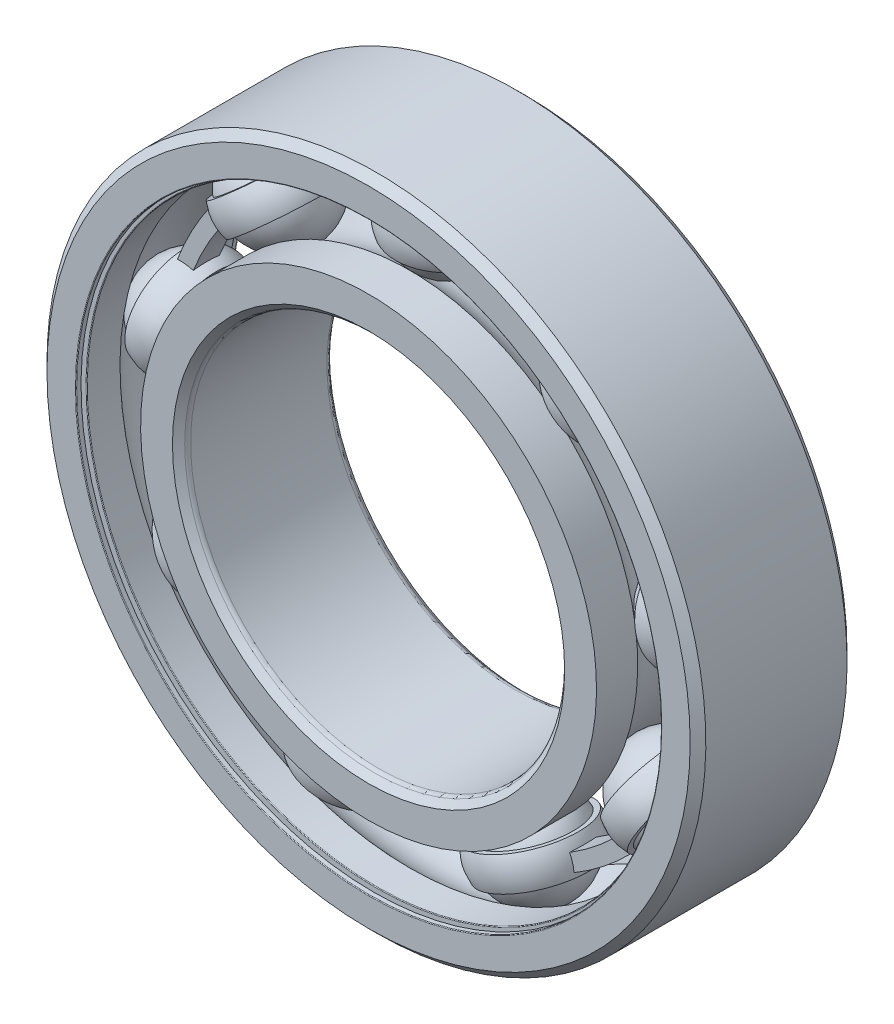
from build123d import *

# Parameters (mm, degrees)
BOSS_EXTRUDE1_DEPTH = 0.416666667
CIRPATTERN1_COUNT   = 9
CIRPATTERN2_COUNT   = 9
FILLET1_R           = 0.0225
FILLET2_R           = 0.1875


with BuildPart() as part:
    # Sketch3 → Revolve1 (revolve)
    with BuildSketch(Plane(origin=(0, 0, 0), x_dir=(0, 0, -1), z_dir=(1, 0, 0))):
        with BuildLine():
            Line((2.25, 10.5), (2.5, 10.25))
            Line((2.5, 10.25), (2.5, 9.234615385))
            Line((2.5, 9.234615385), (1.1875, 9.234615385))
            ThreePointArc((1.1875, 9.234615385), (0, 9.7926029), (-1.1875, 9.234615385))
            Line((-1.1875, 9.234615385), (-2.5, 9.234615385))
            Line((-2.5, 9.234615385), (-2.5, 10.25))
            Line((-2.5, 10.25), (-2.25, 10.5))
            Line((-2.25, 10.5), (2.25, 10.5))
        make_face()
    revolve(axis=Axis((0, 0, 2.5), (0, 0, -1)))

    # Sketch8 → Cut-Revolve1 (revolve, cut)
    with BuildSketch(Plane(origin=(0, 0, 0), x_dir=(0, 0, -1), z_dir=(1, 0, 0))):
        Polygon((-2.34, 9.234615385), (-2.25, 9.234615385), (-2.25, 9.656410256), (-2.34, 9.656410256), (-2.34, 9.324615385), (-2.5, 9.324615385), (-2.5, 9.234615385), align=None)
        Polygon((2.25, 9.234615385), (2.34, 9.234615385), (2.5, 9.234615385), (2.5, 9.324615385), (2.34, 9.324615385), (2.34, 9.656410256), (2.25, 9.656410256), align=None)
    revolve(axis=Axis((0, 0, 2.5), (0, 0, -1)), mode=Mode.SUBTRACT)

    # Fillet1
    fillet1_edges = [part.edges().sort_by_distance(p)[0] for p in [
        (0, -9.324615385, 2.5),
        (0, -9.234615385, 2.25),
        (0, -9.324615385, -2.5),
        (0, -9.234615385, -2.25),
    ]]
    fillet(fillet1_edges, radius=FILLET1_R)


with BuildPart() as body_2:
    # Sketch4 → Revolve2 (revolve)
    with BuildSketch(Plane(origin=(0, 0, 0), x_dir=(0, 0, -1), z_dir=(1, 0, 0))):
        with BuildLine():
            Line((-2.25, 6), (-2.5, 6.25))
            Line((-2.5, 6.25), (-2.5, 7.265384615))
            Line((-2.5, 7.265384615), (-1.1875, 7.265384615))
            ThreePointArc((-1.1875, 7.265384615), (0, 6.7073971), (1.1875, 7.265384615))
            Line((1.1875, 7.265384615), (2.5, 7.265384615))
            Line((2.5, 7.265384615), (2.5, 6.25))
            Line((2.5, 6.25), (2.25, 6))
            Line((2.25, 6), (-2.25, 6))
        make_face()
    revolve(axis=Axis((0, 0, 2.5), (0, 0, -1)))

    # Fillet2
    fillet2_edges = [body_2.edges().sort_by_distance(p)[0] for p in [
        (0, -6, 2.25),
        (0, -6, -2.25),
    ]]
    fillet(fillet2_edges, radius=FILLET2_R)


with BuildPart() as body_3:
    # Sketch5 → Revolve3 (revolve)
    with BuildSketch(Plane(origin=(0, 0, 0), x_dir=(0, 0, -1), z_dir=(1, 0, 0))):
        with BuildLine():
            Line((-1.5426029, 8.25), (1.5426029, 8.25))
            ThreePointArc((1.5426029, 8.25), (0, 9.7926029), (-1.5426029, 8.25))
        make_face()
    revolve(axis=Axis((0, 8.25, 1.5426029), (0, 0, -1)))


with BuildPart() as body_4:
    # Sketch6 → Revolve4 (revolve)
    with BuildSketch(Plane(origin=(0, 0, 0), x_dir=(0, 0, -1), z_dir=(1, 0, 0))):
        with BuildLine():
            Line((-1.461935991, 8.742307692), (-1.634946659, 8.742307692))
            ThreePointArc((-1.634946659, 8.742307692), (-1.721451993, 8.25), (-1.634946659, 7.757692308))
            Line((-1.634946659, 7.757692308), (-1.461935991, 7.757692308))
            ThreePointArc((-1.461935991, 7.757692308), (-1.5426029, 8.25), (-1.461935991, 8.742307692))
        make_face()
    revolve4 = revolve(axis=Axis((0, 10.5, 0), (0, -1, 0)))

    # Sketch7 → Boss-Extrude1 (add, symmetric)
    with BuildSketch(Plane.XY):
        with BuildLine():
            Line((5.30299778, 6.319866656), (5.619447065, 6.696996228))
            ThreePointArc((5.619447065, 6.696996228), (2.99004533, 8.215082027), (0, 8.742307692))
            Line((0, 8.742307692), (0, 8.25))
            ThreePointArc((0, 8.25), (2.821666182, 7.752464121), (5.30299778, 6.319866656))
        make_face()
    boss_extrude1 = extrude(amount=BOSS_EXTRUDE1_DEPTH, both=True)

    # CirPattern2: Revolve4, Boss-Extrude1 ×9 about axis
    cirpattern2_axis = Axis((0, 0, 0), (0, 0, 1))
    for i in range(1, CIRPATTERN2_COUNT):
        add(revolve4.rotate(cirpattern2_axis, i * 360 / CIRPATTERN2_COUNT))
        add(boss_extrude1.rotate(cirpattern2_axis, i * 360 / CIRPATTERN2_COUNT))


with BuildPart() as cirpattern1_1:
    # CirPattern1: pattern copy
    add(body_3.part.rotate(Axis((0, 0, 0), (0, 0, 1)), 1 * 360 / CIRPATTERN1_COUNT))


with BuildPart() as cirpattern1_2:
    # CirPattern1: pattern copy
    add(body_3.part.rotate(Axis((0, 0, 0), (0, 0, 1)), 2 * 360 / CIRPATTERN1_COUNT))


with BuildPart() as cirpattern1_3:
    # CirPattern1: pattern copy
    add(body_3.part.rotate(Axis((0, 0, 0), (0, 0, 1)), 3 * 360 / CIRPATTERN1_COUNT))


with BuildPart() as cirpattern1_4:
    # CirPattern1: pattern copy
    add(body_3.part.rotate(Axis((0, 0, 0), (0, 0, 1)), 4 * 360 / CIRPATTERN1_COUNT))


with BuildPart() as cirpattern1_5:
    # CirPattern1: pattern copy
    add(body_3.part.rotate(Axis((0, 0, 0), (0, 0, 1)), 5 * 360 / CIRPATTERN1_COUNT))


with BuildPart() as cirpattern1_6:
    # CirPattern1: pattern copy
    add(body_3.part.rotate(Axis((0, 0, 0), (0, 0, 1)), 6 * 360 / CIRPATTERN1_COUNT))


with BuildPart() as cirpattern1_7:
    # CirPattern1: pattern copy
    add(body_3.part.rotate(Axis((0, 0, 0), (0, 0, 1)), 7 * 360 / CIRPATTERN1_COUNT))


with BuildPart() as cirpattern1_8:
    # CirPattern1: pattern copy
    add(body_3.part.rotate(Axis((0, 0, 0), (0, 0, 1)), 8 * 360 / CIRPATTERN1_COUNT))


solid = Compound([part.part, body_2.part, body_3.part, body_4.part, cirpattern1_1.part, cirpattern1_2.part, cirpattern1_3.part, cirpattern1_4.part, cirpattern1_5.part, cirpattern1_6.part, cirpattern1_7.part, cirpattern1_8.part])
